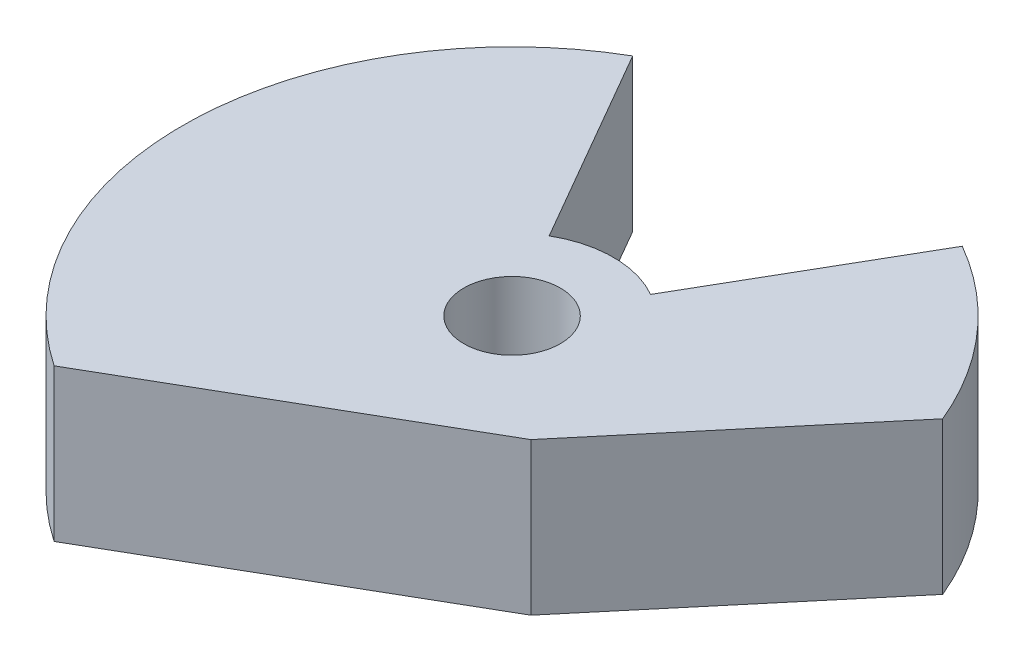
from build123d import *

# Parameters (mm, degrees)
SKETCH1_R           = 4.7625
BOSS_EXTRUDE1_DEPTH = 15
CUT_EXTRUDE1_DEPTH  = 16


with BuildPart() as part:
    # Sketch1 → Boss-Extrude1 (new body)
    with BuildSketch(Plane(origin=(0, 0, 0), x_dir=(1, 0, 0), z_dir=(0, 1, 0))):
        with BuildLine():
            Line((-16.25, 28.145825623), (-5, 8.660254038))
            ThreePointArc((-5, 8.660254038), (0, 10), (5, 8.660254038))
            Line((5, 8.660254038), (16.25, 28.145825623))
            ThreePointArc((16.25, 28.145825623), (0, -32.5), (-16.25, 28.145825623))
        make_face()
        Circle(SKETCH1_R, mode=Mode.SUBTRACT)
    extrude(amount=BOSS_EXTRUDE1_DEPTH)

    # Sketch4 → Cut-Extrude1 (cut, through all)
    with BuildSketch(Plane(origin=(0, 15, 0), x_dir=(1, 0, 0), z_dir=(0, 1, 0))):
        with BuildLine():
            Line((11.490666647, -9.641814145), (45.503789868, 30.893447649))
            ThreePointArc((45.503789868, 30.893447649), (34.992750198, -42.432386612), (-38.992939572, -38.788537785))
            Line((-38.992939572, -38.788537785), (11.490666647, -9.641814145))
        make_face()
    extrude(amount=-CUT_EXTRUDE1_DEPTH, mode=Mode.SUBTRACT)


solid = part.part
